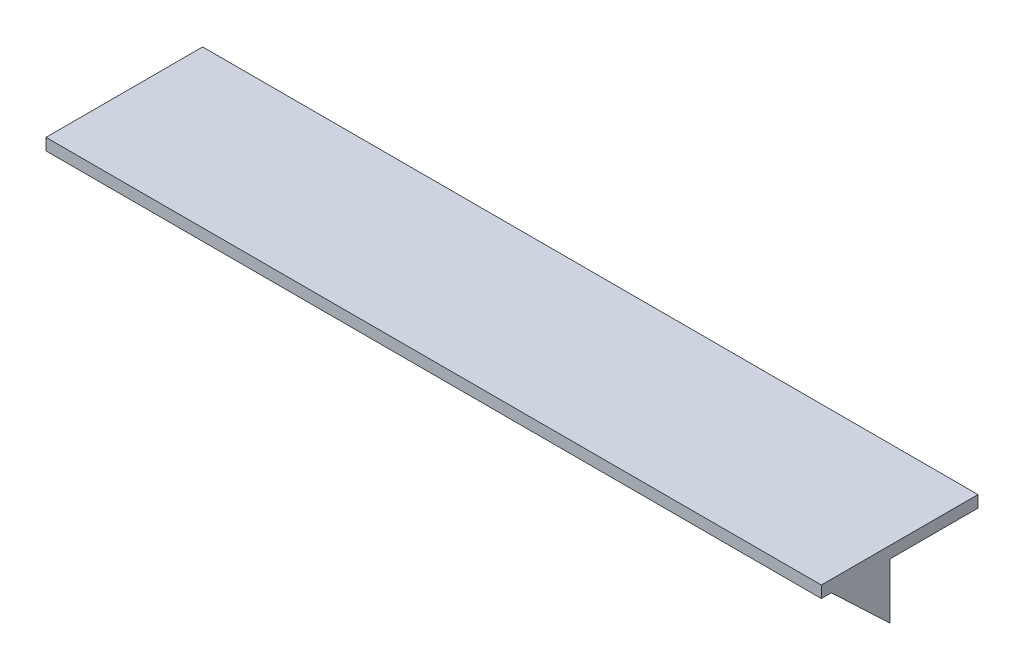
from build123d import *

# Parameters (mm, degrees)
SKETCH1_W           = 198
SKETCH1_H           = 40
BOSS_EXTRUDE1_DEPTH = 3
BOSS_EXTRUDE2_DEPTH = 198


with BuildPart() as part:
    # Sketch1 → Boss-Extrude1 (new body)
    with BuildSketch(Plane(origin=(0, 0, 0), x_dir=(1, 0, 0), z_dir=(0, 1, 0))):
        Rectangle(SKETCH1_W, SKETCH1_H)
    extrude(amount=BOSS_EXTRUDE1_DEPTH)

    # Sketch2 → Boss-Extrude2 (add)
    with BuildSketch(Plane(origin=(-99, 0, 2.522926574), x_dir=(0, 0, 1), z_dir=(-1, 0, 0))):
        Polygon((0, 0), (0, -14.161533961), (14.925088272, 0), align=None)
    extrude(amount=-BOSS_EXTRUDE2_DEPTH)


solid = part.part
